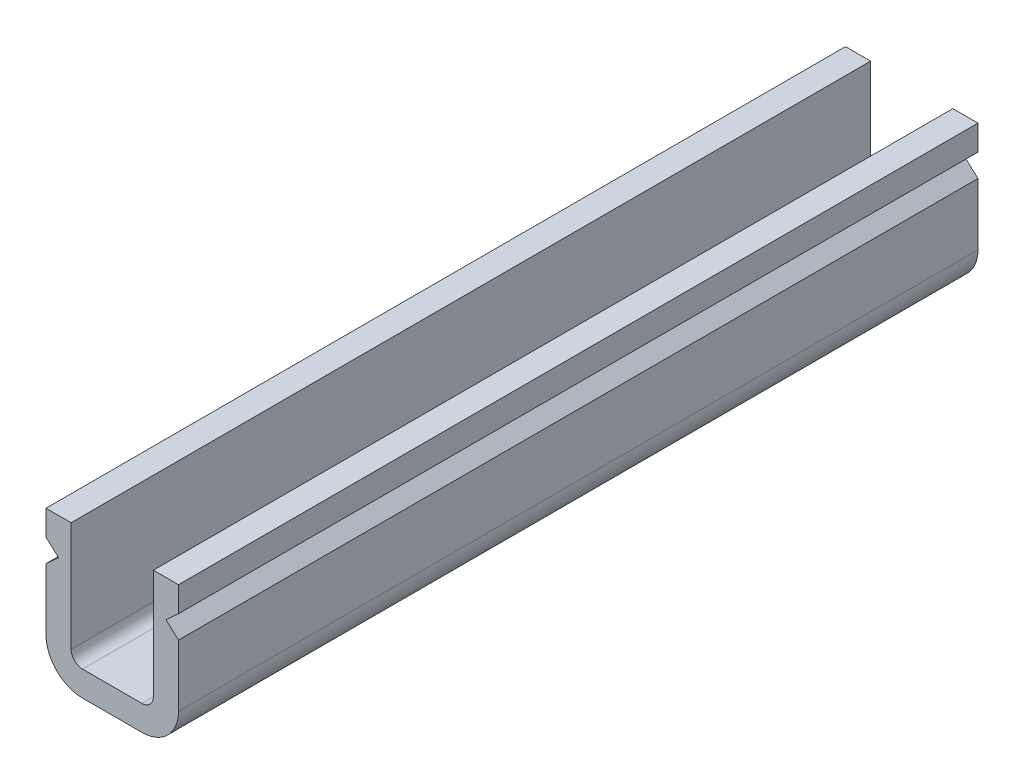
from build123d import *

# Parameters (mm, degrees)
EXTRUSION1_DEPTH = 35


with BuildPart() as part:
    # Esquisse1 → Extrusion1 (new body)
    with BuildSketch(Plane.XY):
        with BuildLine():
            Line((4.7, -4.8), (4.7, 0))
            Line((4.7, 0), (5.8, 0))
            Line((5.8, 0), (5.8, -1.1))
            Line((5.8, -1.1), (5.25, -1.6))
            Line((5.25, -1.6), (5.8, -2.1))
            Line((5.8, -2.1), (5.8, -4.8))
            ThreePointArc((5.8, -4.8), (5.33137085, -5.93137085), (4.2, -6.4))
            Line((4.2, -6.4), (1.6, -6.4))
            ThreePointArc((1.6, -6.4), (0.46862915, -5.93137085), (0, -4.8))
            Line((0, -4.8), (0, -2.1))
            Line((0, -2.1), (0.55, -1.6))
            Line((0.55, -1.6), (0, -1.1))
            Line((0, -1.1), (0, 0))
            Line((0, 0), (1.1, 0))
            Line((1.1, 0), (1.1, -4.8))
            ThreePointArc((1.1, -4.8), (1.246446609, -5.153553391), (1.6, -5.3))
            Line((1.6, -5.3), (4.2, -5.3))
            ThreePointArc((4.2, -5.3), (4.553553391, -5.153553391), (4.7, -4.8))
        make_face()
    extrude(amount=EXTRUSION1_DEPTH)


solid = part.part
